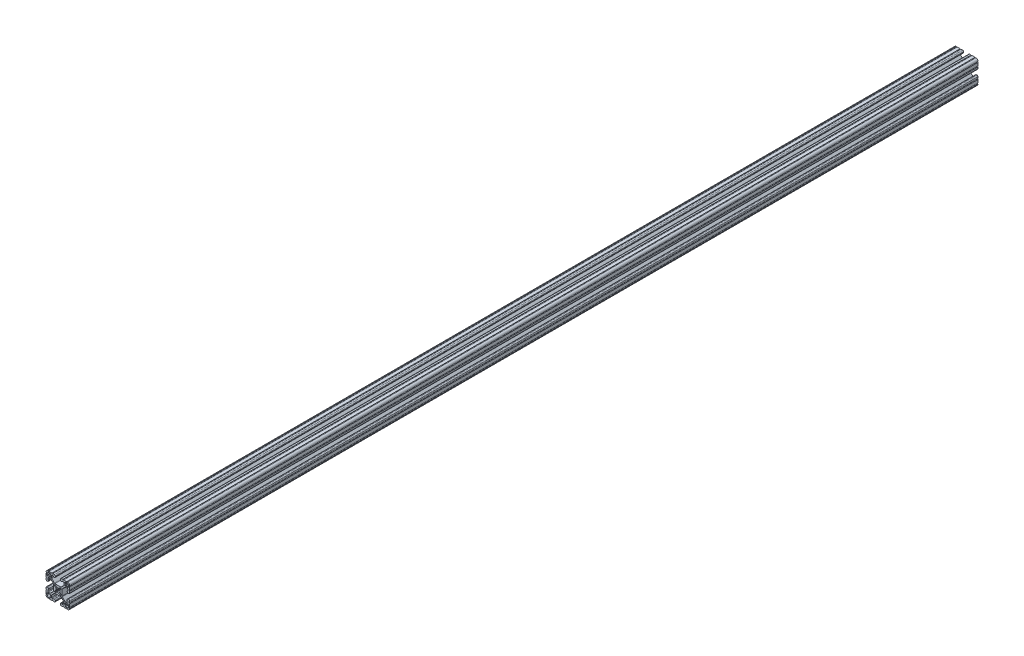
from build123d import *

# Parameters (mm, degrees)
EXTRUDE1_DEPTH = 1460.5


with BuildPart() as part:
    # Sketch1 → Extrude1 (new body)
    with BuildSketch(Plane.XY):
        with BuildLine():
            Line((6.349777007, -14.984831919), (5.653061318, -14.984831848))
            ThreePointArc((5.653061318, -14.984831848), (4.539002167, -15.446080098), (4.077754017, -16.560139291))
            Line((4.077754017, -16.560139291), (4.077753935, -17.474692556))
            ThreePointArc((4.077753935, -17.474692556), (4.539002158, -18.588751741), (5.653061362, -19.049999918))
            Line((5.653061362, -19.049999918), (7.975599859, -19.05))
            ThreePointArc((7.975599859, -19.05), (8.737599929, -18.288), (9.4996, -19.05))
            Line((9.4996, -19.05), (14.298091988, -19.05))
            ThreePointArc((14.298091988, -19.05), (15.05987163, -18.288000032), (15.822092002, -19.049559142))
            ThreePointArc((15.822092002, -19.049559142), (18.110316678, -18.129769245), (19.049898398, -15.849599993))
            ThreePointArc((19.049898398, -15.849599993), (18.288000002, -15.087549199), (19.05, -14.3256))
            Line((19.05, -14.3256), (19.05, -9.499600141))
            ThreePointArc((19.05, -9.499600141), (18.288, -8.737600071), (19.05, -7.9756))
            Line((19.05, -7.9756), (19.05, -5.653061359))
            ThreePointArc((19.05, -5.653061359), (18.588751763, -4.53900218), (17.474692553, -4.077754017))
            Line((17.474692553, -4.077754017), (16.560139293, -4.077753935))
            ThreePointArc((16.560139293, -4.077753935), (15.446080122, -4.539002143), (14.98483193, -5.653061321))
            Line((14.98483193, -5.653061321), (14.984831848, -6.349776986))
            ThreePointArc((14.984831848, -6.349776986), (15.096428348, -6.619420887), (15.366075744, -6.731008942))
            Line((15.366075744, -6.731008942), (15.696937609, -6.730998691))
            ThreePointArc((15.696937609, -6.730998691), (15.966583472, -6.842585282), (16.078181438, -7.112226438))
            Line((16.078181438, -7.112226438), (16.078207121, -9.396837814))
            ThreePointArc((16.078207121, -9.396837814), (15.817838504, -10.026619018), (15.188068118, -10.287013801))
            Line((15.188068118, -10.287013801), (12.352560476, -10.287103022))
            ThreePointArc((12.352560476, -10.287103022), (11.865894357, -10.190173629), (11.453520834, -9.914153164))
            Line((11.453520834, -9.914153164), (7.114725376, -5.565926641))
            ThreePointArc((7.114725376, -5.565926641), (6.840134749, -5.154247475), (6.7437254, -4.668876499))
            Line((6.7437254, -4.668876499), (6.7437254, 4.641368628))
            ThreePointArc((6.7437254, 4.641368628), (6.840134749, 5.126739605), (7.114725376, 5.53841877))
            Line((7.114725376, 5.53841877), (11.480968187, 9.914152308))
            ThreePointArc((11.480968187, 9.914152308), (11.89334171, 10.190172773), (12.380007829, 10.287102166))
            Line((12.380007829, 10.287102166), (15.188068116, 10.287014567))
            ThreePointArc((15.188068116, 10.287014567), (15.817838279, 10.026619243), (16.078206356, 9.396837815))
            Line((16.078206356, 9.396837815), (16.078181509, 7.1122265))
            ThreePointArc((16.078181509, 7.1122265), (15.966583514, 6.842585324), (15.696937607, 6.730998762))
            Line((15.696937607, 6.730998762), (15.366075744, 6.731009012))
            ThreePointArc((15.366075744, 6.731009012), (15.096428376, 6.619420915), (14.984831919, 6.349777007))
            Line((14.984831919, 6.349777007), (14.984831848, 5.653061318))
            ThreePointArc((14.984831848, 5.653061318), (15.446080098, 4.539002167), (16.560139291, 4.077754017))
            Line((16.560139291, 4.077754017), (17.474692556, 4.077753935))
            ThreePointArc((17.474692556, 4.077753935), (18.588751741, 4.539002158), (19.049999918, 5.653061362))
            Line((19.049999918, 5.653061362), (19.05, 7.975599859))
            ThreePointArc((19.05, 7.975599859), (18.288, 8.737599929), (19.05, 9.4996))
            Line((19.05, 9.4996), (19.05, 14.298091988))
            ThreePointArc((19.05, 14.298091988), (18.288000032, 15.05987163), (19.049559142, 15.822092002))
            ThreePointArc((19.049559142, 15.822092002), (18.129769245, 18.110316678), (15.849599993, 19.049898398))
            ThreePointArc((15.849599993, 19.049898398), (15.087549199, 18.288000002), (14.3256, 19.05))
            Line((14.3256, 19.05), (9.499600141, 19.05))
            ThreePointArc((9.499600141, 19.05), (8.737600071, 18.288), (7.9756, 19.05))
            Line((7.9756, 19.05), (5.653061359, 19.05))
            ThreePointArc((5.653061359, 19.05), (4.53900218, 18.588751763), (4.077754017, 17.474692553))
            Line((4.077754017, 17.474692553), (4.077753935, 16.560139293))
            ThreePointArc((4.077753935, 16.560139293), (4.539002143, 15.446080122), (5.653061321, 14.98483193))
            Line((5.653061321, 14.98483193), (6.349776986, 14.984831848))
            ThreePointArc((6.349776986, 14.984831848), (6.619420887, 15.096428348), (6.731008942, 15.366075744))
            Line((6.731008942, 15.366075744), (6.730998691, 15.696937609))
            ThreePointArc((6.730998691, 15.696937609), (6.842585282, 15.966583472), (7.112226438, 16.078181438))
            Line((7.112226438, 16.078181438), (9.396837814, 16.078207121))
            ThreePointArc((9.396837814, 16.078207121), (10.026619018, 15.817838504), (10.287013801, 15.188068118))
            Line((10.287013801, 15.188068118), (10.287103022, 12.352560476))
            ThreePointArc((10.287103022, 12.352560476), (10.190173629, 11.865894357), (9.914153164, 11.453520834))
            Line((9.914153164, 11.453520834), (5.565926641, 7.114725376))
            ThreePointArc((5.565926641, 7.114725376), (5.154247475, 6.840134749), (4.668876499, 6.7437254))
            Line((4.668876499, 6.7437254), (-4.641368628, 6.7437254))
            ThreePointArc((-4.641368628, 6.7437254), (-5.126739605, 6.840134749), (-5.53841877, 7.114725376))
            Line((-5.53841877, 7.114725376), (-9.914152308, 11.480968187))
            ThreePointArc((-9.914152308, 11.480968187), (-10.190172773, 11.89334171), (-10.287102166, 12.380007829))
            Line((-10.287102166, 12.380007829), (-10.287014567, 15.188068116))
            ThreePointArc((-10.287014567, 15.188068116), (-10.026619243, 15.817838279), (-9.396837815, 16.078206356))
            Line((-9.396837815, 16.078206356), (-7.1122265, 16.078181509))
            ThreePointArc((-7.1122265, 16.078181509), (-6.842585324, 15.966583514), (-6.730998762, 15.696937607))
            Line((-6.730998762, 15.696937607), (-6.731008942, 15.366075744))
            ThreePointArc((-6.731008942, 15.366075744), (-6.619420905, 15.096428366), (-6.349777007, 14.984831919))
            Line((-6.349777007, 14.984831919), (-5.653061318, 14.984831848))
            ThreePointArc((-5.653061318, 14.984831848), (-4.539002167, 15.446080098), (-4.077754017, 16.560139291))
            Line((-4.077754017, 16.560139291), (-4.077753935, 17.474692556))
            ThreePointArc((-4.077753935, 17.474692556), (-4.539002158, 18.588751741), (-5.653061362, 19.049999918))
            Line((-5.653061362, 19.049999918), (-7.975599859, 19.05))
            ThreePointArc((-7.975599859, 19.05), (-8.737599929, 18.288), (-9.4996, 19.05))
            Line((-9.4996, 19.05), (-14.298091988, 19.05))
            ThreePointArc((-14.298091988, 19.05), (-15.05987163, 18.288000032), (-15.822092002, 19.049559142))
            ThreePointArc((-15.822092002, 19.049559142), (-18.110316678, 18.129769245), (-19.049898398, 15.849599993))
            ThreePointArc((-19.049898398, 15.849599993), (-18.288000002, 15.087549199), (-19.05, 14.3256))
            Line((-19.05, 14.3256), (-19.05, 9.499600141))
            ThreePointArc((-19.05, 9.499600141), (-18.288, 8.737600071), (-19.05, 7.9756))
            Line((-19.05, 7.9756), (-19.05, 5.653061359))
            ThreePointArc((-19.05, 5.653061359), (-18.588751763, 4.53900218), (-17.474692553, 4.077754017))
            Line((-17.474692553, 4.077754017), (-16.560139293, 4.077753935))
            ThreePointArc((-16.560139293, 4.077753935), (-15.446080122, 4.539002143), (-14.98483193, 5.653061321))
            Line((-14.98483193, 5.653061321), (-14.984831848, 6.349776986))
            ThreePointArc((-14.984831848, 6.349776986), (-15.096428348, 6.619420887), (-15.366075744, 6.731008942))
            Line((-15.366075744, 6.731008942), (-15.696937609, 6.730998691))
            ThreePointArc((-15.696937609, 6.730998691), (-15.966583472, 6.842585283), (-16.078181438, 7.112226438))
            Line((-16.078181438, 7.112226438), (-16.078207121, 9.396837814))
            ThreePointArc((-16.078207121, 9.396837814), (-15.817838504, 10.026619018), (-15.188068118, 10.287013802))
            Line((-15.188068118, 10.287013802), (-12.352560476, 10.287103022))
            ThreePointArc((-12.352560476, 10.287103022), (-11.865894357, 10.190173629), (-11.453520834, 9.914153164))
            Line((-11.453520834, 9.914153164), (-7.114725376, 5.565926641))
            ThreePointArc((-7.114725376, 5.565926641), (-6.840134749, 5.154247475), (-6.7437254, 4.668876499))
            Line((-6.7437254, 4.668876499), (-6.7437254, -4.641368628))
            ThreePointArc((-6.7437254, -4.641368628), (-6.840134749, -5.126739605), (-7.114725376, -5.53841877))
            Line((-7.114725376, -5.53841877), (-11.480968187, -9.914152308))
            ThreePointArc((-11.480968187, -9.914152308), (-11.89334171, -10.190172773), (-12.380007829, -10.287102166))
            Line((-12.380007829, -10.287102166), (-15.188068116, -10.287014567))
            ThreePointArc((-15.188068116, -10.287014567), (-15.817838279, -10.026619243), (-16.078206356, -9.396837815))
            Line((-16.078206356, -9.396837815), (-16.078181509, -7.1122265))
            ThreePointArc((-16.078181509, -7.1122265), (-15.966583514, -6.842585324), (-15.696937607, -6.730998762))
            Line((-15.696937607, -6.730998762), (-15.366075744, -6.731009012))
            ThreePointArc((-15.366075744, -6.731009012), (-15.096428376, -6.619420915), (-14.984831919, -6.349777007))
            Line((-14.984831919, -6.349777007), (-14.984831848, -5.653061318))
            ThreePointArc((-14.984831848, -5.653061318), (-15.446080098, -4.539002167), (-16.560139291, -4.077754017))
            Line((-16.560139291, -4.077754017), (-17.474692556, -4.077753935))
            ThreePointArc((-17.474692556, -4.077753935), (-18.588751741, -4.539002158), (-19.049999918, -5.653061362))
            Line((-19.049999918, -5.653061362), (-19.05, -7.975599859))
            ThreePointArc((-19.05, -7.975599859), (-18.288, -8.737599929), (-19.05, -9.4996))
            Line((-19.05, -9.4996), (-19.05, -14.298091988))
            ThreePointArc((-19.05, -14.298091988), (-18.288000032, -15.05987163), (-19.049559142, -15.822092002))
            ThreePointArc((-19.049559142, -15.822092002), (-18.129769245, -18.110316678), (-15.849599993, -19.049898398))
            ThreePointArc((-15.849599993, -19.049898398), (-15.087549199, -18.288000002), (-14.3256, -19.05))
            Line((-14.3256, -19.05), (-9.499600141, -19.05))
            ThreePointArc((-9.499600141, -19.05), (-8.737600071, -18.288), (-7.9756, -19.05))
            Line((-7.9756, -19.05), (-5.653061359, -19.05))
            ThreePointArc((-5.653061359, -19.05), (-4.53900218, -18.588751763), (-4.077754017, -17.474692553))
            Line((-4.077754017, -17.474692553), (-4.077753935, -16.560139293))
            ThreePointArc((-4.077753935, -16.560139293), (-4.539002143, -15.446080122), (-5.653061321, -14.98483193))
            Line((-5.653061321, -14.98483193), (-6.349776986, -14.984831848))
            ThreePointArc((-6.349776986, -14.984831848), (-6.619420887, -15.096428348), (-6.731008942, -15.366075744))
            Line((-6.731008942, -15.366075744), (-6.730998691, -15.696937609))
            ThreePointArc((-6.730998691, -15.696937609), (-6.842585282, -15.966583472), (-7.112226438, -16.078181438))
            Line((-7.112226438, -16.078181438), (-9.396837814, -16.078207121))
            ThreePointArc((-9.396837814, -16.078207121), (-10.026619018, -15.817838504), (-10.287013801, -15.188068118))
            Line((-10.287013801, -15.188068118), (-10.287103022, -12.352560476))
            ThreePointArc((-10.287103022, -12.352560476), (-10.190173629, -11.865894357), (-9.914153164, -11.453520834))
            Line((-9.914153164, -11.453520834), (-5.565926641, -7.114725376))
            ThreePointArc((-5.565926641, -7.114725376), (-5.154247475, -6.840134749), (-4.668876499, -6.7437254))
            Line((-4.668876499, -6.7437254), (4.641368628, -6.7437254))
            ThreePointArc((4.641368628, -6.7437254), (5.126739605, -6.840134749), (5.53841877, -7.114725376))
            Line((5.53841877, -7.114725376), (9.914152308, -11.480968187))
            ThreePointArc((9.914152308, -11.480968187), (10.190172773, -11.89334171), (10.287102166, -12.380007829))
            Line((10.287102166, -12.380007829), (10.287014567, -15.188068116))
            ThreePointArc((10.287014567, -15.188068116), (10.026619243, -15.817838279), (9.396837815, -16.078206356))
            Line((9.396837815, -16.078206356), (7.1122265, -16.078181509))
            ThreePointArc((7.1122265, -16.078181509), (6.842585324, -15.966583514), (6.730998762, -15.696937607))
            Line((6.730998762, -15.696937607), (6.731008942, -15.366075744))
            ThreePointArc((6.731008942, -15.366075744), (6.619420905, -15.096428366), (6.349777007, -14.984831919))
        make_face()
        with BuildLine():
            Line((1.582347442, 3.198793543), (3.292097227, 4.908543328))
            ThreePointArc((3.292097227, 4.908543328), (3.580509584, 5.101254304), (3.920715155, 5.1689254))
            Line((3.920715155, 5.1689254), (4.9149254, 5.1689254))
            ThreePointArc((4.9149254, 5.1689254), (5.094530522, 5.094530522), (5.1689254, 4.9149254))
            Line((5.1689254, 4.9149254), (5.1689254, 3.920715155))
            ThreePointArc((5.1689254, 3.920715155), (5.101254304, 3.580509584), (4.908543328, 3.292097227))
            Line((4.908543328, 3.292097227), (3.198793543, 1.582347442))
            ThreePointArc((3.198793543, 1.582347442), (3.095711236, 1.393016011), (3.111879183, 1.178048687))
            ThreePointArc((3.111879183, 1.178048687), (3.3274, 0), (3.111879183, -1.178048687))
            ThreePointArc((3.111879183, -1.178048687), (3.095711236, -1.393016011), (3.198793543, -1.582347442))
            Line((3.198793543, -1.582347442), (4.908543328, -3.292097227))
            ThreePointArc((4.908543328, -3.292097227), (5.101254304, -3.580509584), (5.1689254, -3.920715155))
            Line((5.1689254, -3.920715155), (5.1689254, -4.9149254))
            ThreePointArc((5.1689254, -4.9149254), (5.094530522, -5.094530522), (4.9149254, -5.1689254))
            Line((4.9149254, -5.1689254), (3.920715155, -5.1689254))
            ThreePointArc((3.920715155, -5.1689254), (3.580509584, -5.101254304), (3.292097227, -4.908543328))
            Line((3.292097227, -4.908543328), (1.582347442, -3.198793543))
            ThreePointArc((1.582347442, -3.198793543), (1.393016011, -3.095711236), (1.178048687, -3.111879183))
            ThreePointArc((1.178048687, -3.111879183), (0, -3.3274), (-1.178048687, -3.111879183))
            ThreePointArc((-1.178048687, -3.111879183), (-1.393016011, -3.095711236), (-1.582347442, -3.198793543))
            Line((-1.582347442, -3.198793543), (-3.292097227, -4.908543328))
            ThreePointArc((-3.292097227, -4.908543328), (-3.580509584, -5.101254304), (-3.920715155, -5.1689254))
            Line((-3.920715155, -5.1689254), (-4.9149254, -5.1689254))
            ThreePointArc((-4.9149254, -5.1689254), (-5.094530522, -5.094530522), (-5.1689254, -4.9149254))
            Line((-5.1689254, -4.9149254), (-5.1689254, -3.920715155))
            ThreePointArc((-5.1689254, -3.920715155), (-5.101254304, -3.580509584), (-4.908543328, -3.292097227))
            Line((-4.908543328, -3.292097227), (-3.198793543, -1.582347442))
            ThreePointArc((-3.198793543, -1.582347442), (-3.095711236, -1.393016011), (-3.111879183, -1.178048687))
            ThreePointArc((-3.111879183, -1.178048687), (-3.3274, 0), (-3.111879183, 1.178048687))
            ThreePointArc((-3.111879183, 1.178048687), (-3.095711236, 1.393016011), (-3.198793543, 1.582347442))
            Line((-3.198793543, 1.582347442), (-4.908543328, 3.292097227))
            ThreePointArc((-4.908543328, 3.292097227), (-5.101254304, 3.580509584), (-5.1689254, 3.920715155))
            Line((-5.1689254, 3.920715155), (-5.1689254, 4.9149254))
            ThreePointArc((-5.1689254, 4.9149254), (-5.094530522, 5.094530522), (-4.9149254, 5.1689254))
            Line((-4.9149254, 5.1689254), (-3.920715155, 5.1689254))
            ThreePointArc((-3.920715155, 5.1689254), (-3.580509584, 5.101254304), (-3.292097227, 4.908543328))
            Line((-3.292097227, 4.908543328), (-1.582347442, 3.198793543))
            ThreePointArc((-1.582347442, 3.198793543), (-1.393016011, 3.095711236), (-1.178048687, 3.111879183))
            ThreePointArc((-1.178048687, 3.111879183), (0, 3.3274), (1.178048687, 3.111879183))
            ThreePointArc((1.178048687, 3.111879183), (1.393016011, 3.095711236), (1.582347442, 3.198793543))
        make_face(mode=Mode.SUBTRACT)
        with BuildLine():
            Line((-11.8669054, 14.019430433), (-11.8669054, 12.24788))
            ThreePointArc((-11.8669054, 12.24788), (-11.978497716, 11.978472316), (-12.2479054, 11.86688))
            Line((-12.2479054, 11.86688), (-14.019455833, 11.86688))
            ThreePointArc((-14.019455833, 11.86688), (-14.020427836, 11.867073341), (-14.021251865, 11.867623929))
            Line((-14.021251865, 11.867623929), (-14.557512425, 12.403872831))
            ThreePointArc((-14.557512425, 12.403872831), (-14.559308484, 12.404616761), (-14.561104527, 12.403872792))
            Line((-14.561104527, 12.403872792), (-15.097341694, 11.867623968))
            ThreePointArc((-15.097341694, 11.867623968), (-15.098165736, 11.867073351), (-15.099137765, 11.86688))
            Line((-15.099137765, 11.86688), (-16.8707054, 11.86688))
            ThreePointArc((-16.8707054, 11.86688), (-17.140113084, 11.978472316), (-17.2517054, 12.24788))
            Line((-17.2517054, 12.24788), (-17.2517054, 14.45768))
            ThreePointArc((-17.2517054, 14.45768), (-16.433361747, 16.433336347), (-14.4577054, 17.25168))
            Line((-14.4577054, 17.25168), (-12.2479054, 17.25168))
            ThreePointArc((-12.2479054, 17.25168), (-11.978497716, 17.140087684), (-11.8669054, 16.87068))
            Line((-11.8669054, 16.87068), (-11.8669054, 15.099112365))
            ThreePointArc((-11.8669054, 15.099112365), (-11.867098751, 15.098140336), (-11.867649368, 15.097316294))
            Line((-11.867649368, 15.097316294), (-12.403898192, 14.561079127))
            ThreePointArc((-12.403898192, 14.561079127), (-12.40464216, 14.559283084), (-12.403898231, 14.557487025))
            Line((-12.403898231, 14.557487025), (-11.867649329, 14.021226465))
            ThreePointArc((-11.867649329, 14.021226465), (-11.867098741, 14.020402437), (-11.8669054, 14.019430433))
        make_face(mode=Mode.SUBTRACT)
        with BuildLine():
            Line((-14.019430433, -11.8669054), (-12.24788, -11.8669054))
            ThreePointArc((-12.24788, -11.8669054), (-11.978472316, -11.978497716), (-11.86688, -12.2479054))
            Line((-11.86688, -12.2479054), (-11.86688, -14.019455833))
            ThreePointArc((-11.86688, -14.019455833), (-11.867073341, -14.020427836), (-11.867623929, -14.021251865))
            Line((-11.867623929, -14.021251865), (-12.403872831, -14.557512425))
            ThreePointArc((-12.403872831, -14.557512425), (-12.404616761, -14.559308484), (-12.403872792, -14.561104527))
            Line((-12.403872792, -14.561104527), (-11.867623968, -15.097341694))
            ThreePointArc((-11.867623968, -15.097341694), (-11.867073351, -15.098165736), (-11.86688, -15.099137765))
            Line((-11.86688, -15.099137765), (-11.86688, -16.8707054))
            ThreePointArc((-11.86688, -16.8707054), (-11.978472316, -17.140113083), (-12.24788, -17.2517054))
            Line((-12.24788, -17.2517054), (-14.45768, -17.2517054))
            ThreePointArc((-14.45768, -17.2517054), (-16.433336347, -16.433361746), (-17.25168, -14.4577054))
            Line((-17.25168, -14.4577054), (-17.25168, -12.2479054))
            ThreePointArc((-17.25168, -12.2479054), (-17.140087684, -11.978497716), (-16.87068, -11.8669054))
            Line((-16.87068, -11.8669054), (-15.099112365, -11.8669054))
            ThreePointArc((-15.099112365, -11.8669054), (-15.098140336, -11.867098751), (-15.097316294, -11.867649368))
            Line((-15.097316294, -11.867649368), (-14.561079127, -12.403898192))
            ThreePointArc((-14.561079127, -12.403898192), (-14.559283084, -12.40464216), (-14.557487025, -12.403898231))
            Line((-14.557487025, -12.403898231), (-14.021226465, -11.867649329))
            ThreePointArc((-14.021226465, -11.867649329), (-14.020402437, -11.867098741), (-14.019430433, -11.8669054))
        make_face(mode=Mode.SUBTRACT)
        with BuildLine():
            Line((11.8669054, -14.019430433), (11.8669054, -12.24788))
            ThreePointArc((11.8669054, -12.24788), (11.978497716, -11.978472316), (12.2479054, -11.86688))
            Line((12.2479054, -11.86688), (14.019455833, -11.86688))
            ThreePointArc((14.019455833, -11.86688), (14.020427836, -11.867073341), (14.021251865, -11.867623929))
            Line((14.021251865, -11.867623929), (14.557512425, -12.403872831))
            ThreePointArc((14.557512425, -12.403872831), (14.559308484, -12.404616761), (14.561104527, -12.403872792))
            Line((14.561104527, -12.403872792), (15.097341694, -11.867623968))
            ThreePointArc((15.097341694, -11.867623968), (15.098165736, -11.867073351), (15.099137765, -11.86688))
            Line((15.099137765, -11.86688), (16.8707054, -11.86688))
            ThreePointArc((16.8707054, -11.86688), (17.140113084, -11.978472316), (17.2517054, -12.24788))
            Line((17.2517054, -12.24788), (17.2517054, -14.45768))
            ThreePointArc((17.2517054, -14.45768), (16.433361747, -16.433336347), (14.4577054, -17.25168))
            Line((14.4577054, -17.25168), (12.2479054, -17.25168))
            ThreePointArc((12.2479054, -17.25168), (11.978497716, -17.140087684), (11.8669054, -16.87068))
            Line((11.8669054, -16.87068), (11.8669054, -15.099112365))
            ThreePointArc((11.8669054, -15.099112365), (11.867098751, -15.098140336), (11.867649368, -15.097316294))
            Line((11.867649368, -15.097316294), (12.403898192, -14.561079127))
            ThreePointArc((12.403898192, -14.561079127), (12.40464216, -14.559283084), (12.403898231, -14.557487025))
            Line((12.403898231, -14.557487025), (11.867649329, -14.021226465))
            ThreePointArc((11.867649329, -14.021226465), (11.867098741, -14.020402436), (11.8669054, -14.019430433))
        make_face(mode=Mode.SUBTRACT)
        with BuildLine():
            Line((14.019430433, 11.8669054), (12.24788, 11.8669054))
            ThreePointArc((12.24788, 11.8669054), (11.978472316, 11.978497716), (11.86688, 12.2479054))
            Line((11.86688, 12.2479054), (11.86688, 14.019455833))
            ThreePointArc((11.86688, 14.019455833), (11.867073341, 14.020427836), (11.867623929, 14.021251865))
            Line((11.867623929, 14.021251865), (12.403872831, 14.557512425))
            ThreePointArc((12.403872831, 14.557512425), (12.404616761, 14.559308484), (12.403872792, 14.561104527))
            Line((12.403872792, 14.561104527), (11.867623968, 15.097341694))
            ThreePointArc((11.867623968, 15.097341694), (11.867073351, 15.098165736), (11.86688, 15.099137765))
            Line((11.86688, 15.099137765), (11.86688, 16.8707054))
            ThreePointArc((11.86688, 16.8707054), (11.978472316, 17.140113084), (12.24788, 17.2517054))
            Line((12.24788, 17.2517054), (14.45768, 17.2517054))
            ThreePointArc((14.45768, 17.2517054), (16.433336347, 16.433361747), (17.25168, 14.4577054))
            Line((17.25168, 14.4577054), (17.25168, 12.2479054))
            ThreePointArc((17.25168, 12.2479054), (17.140087684, 11.978497716), (16.87068, 11.8669054))
            Line((16.87068, 11.8669054), (15.099112365, 11.8669054))
            ThreePointArc((15.099112365, 11.8669054), (15.098140336, 11.867098751), (15.097316294, 11.867649368))
            Line((15.097316294, 11.867649368), (14.561079127, 12.403898192))
            ThreePointArc((14.561079127, 12.403898192), (14.559283084, 12.404642161), (14.557487025, 12.403898231))
            Line((14.557487025, 12.403898231), (14.021226465, 11.867649329))
            ThreePointArc((14.021226465, 11.867649329), (14.020402436, 11.867098741), (14.019430433, 11.8669054))
        make_face(mode=Mode.SUBTRACT)
    extrude(amount=-EXTRUDE1_DEPTH)


solid = part.part
